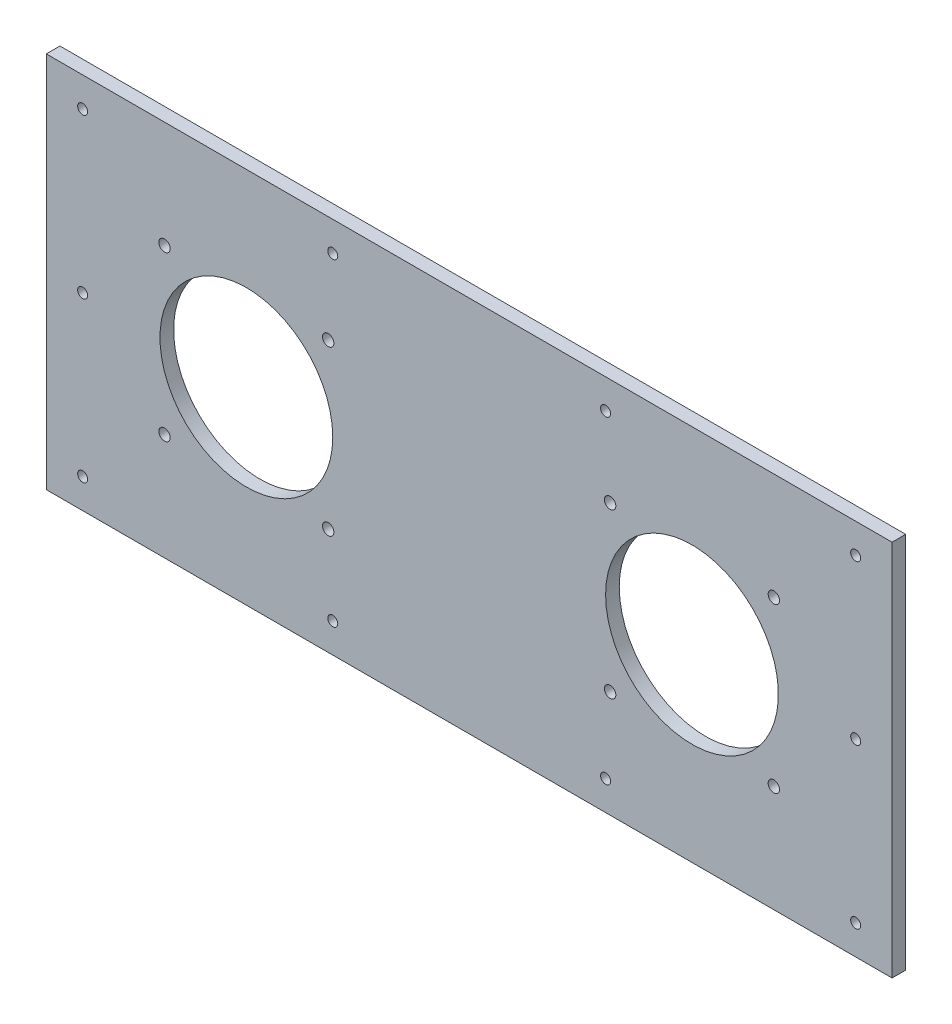
from build123d import *

# Parameters (mm, degrees)
ESQUISSE1_W             = 372
ESQUISSE1_H             = 166
ESQUISSE1_R             = 2.2
BOSS_EXTRU_1_DEPTH      = 6
ESQUISSE2_R             = 38
ESQUISSE2_R_2           = 2.5
ENL_V_MAT_EXTRU_1_DEPTH = 7


with BuildPart() as part:
    # Esquisse1 → Boss.-Extru.1 (new body)
    with BuildSketch(Plane.XY):
        Rectangle(ESQUISSE1_W, ESQUISSE1_H)
        with Locations((-170, 70)):
            Circle(ESQUISSE1_R, mode=Mode.SUBTRACT)
        with Locations((-60, 70)):
            Circle(ESQUISSE1_R, mode=Mode.SUBTRACT)
        with Locations((60, 70)):
            Circle(ESQUISSE1_R, mode=Mode.SUBTRACT)
        with Locations((170, 70)):
            Circle(ESQUISSE1_R, mode=Mode.SUBTRACT)
        with Locations((170, -70)):
            Circle(ESQUISSE1_R, mode=Mode.SUBTRACT)
        with Locations((60, -70)):
            Circle(ESQUISSE1_R, mode=Mode.SUBTRACT)
        with Locations((-60, -70)):
            Circle(ESQUISSE1_R, mode=Mode.SUBTRACT)
        with Locations((-170, -70)):
            Circle(ESQUISSE1_R, mode=Mode.SUBTRACT)
        with Locations((-170, 0)):
            Circle(ESQUISSE1_R, mode=Mode.SUBTRACT)
        with Locations((170, 0)):
            Circle(ESQUISSE1_R, mode=Mode.SUBTRACT)
    extrude(amount=BOSS_EXTRU_1_DEPTH)

    # Esquisse2 → Enlèv. mat.-Extru.1 (cut, through all)
    with BuildSketch(Plane.XY.offset(6)):
        with Locations((-98, 0)):
            Circle(ESQUISSE2_R)
        with Locations((-134, 36)):
            Circle(ESQUISSE2_R_2)
        with Locations((-134, -36)):
            Circle(ESQUISSE2_R_2)
        with Locations((-62, -36)):
            Circle(ESQUISSE2_R_2)
        with Locations((-62, 36)):
            Circle(ESQUISSE2_R_2)
        with Locations((62, 36)):
            Circle(ESQUISSE2_R_2)
        with Locations((62, -36)):
            Circle(ESQUISSE2_R_2)
        with Locations((134, -36)):
            Circle(ESQUISSE2_R_2)
        with Locations((134, 36)):
            Circle(ESQUISSE2_R_2)
        with Locations((98, 0)):
            Circle(ESQUISSE2_R)
    extrude(amount=-ENL_V_MAT_EXTRU_1_DEPTH, mode=Mode.SUBTRACT)


solid = part.part
